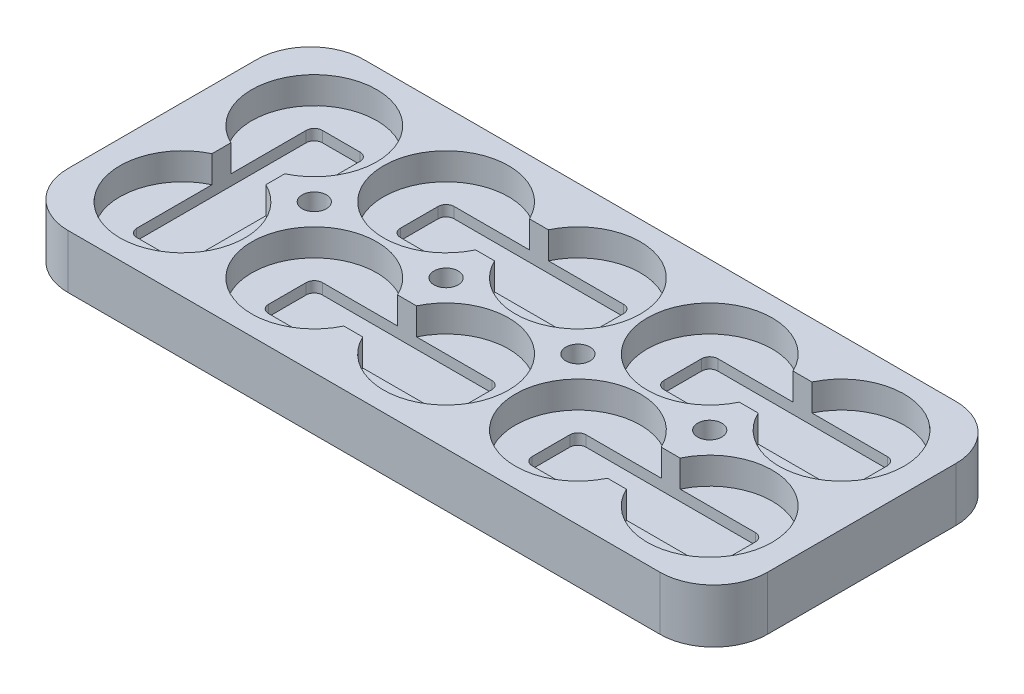
from build123d import *

# Parameters (mm, degrees)
SKIZZE1_W                                   = 130
SKIZZE1_H                                   = 55
AUFSATZ_LINEAR_AUSTRAGEN1_DEPTH             = 10
VERRUNDUNG1_R                               = 10
DURCHGANGSLOCH_F_R_M41_D                    = 4.5
SKIZZE3_R                                   = 11.625
SCHNITT_LINEAR_AUSTRAGEN1_DEPTH             = 5
SKIZZE8_W                                   = 34.5
SKIZZE8_H                                   = 10
SKIZZE8_W_2                                 = 10
SKIZZE8_H_2                                 = 34.5
SCHNITT_LINEAR_AUSTRAGEN3_DEPTH             = 2
SCHNITT_LINEAR_AUSTRAGEN3_DIRECTION_2_REACH = 7
VERRUNDUNG3_R                               = 1.5


with BuildPart() as part:
    # Skizze1 → Aufsatz-Linear austragen1 (new body)
    with BuildSketch(Plane(origin=(0, 0, 0), x_dir=(1, 0, 0), z_dir=(0, 1, 0))):
        with Locations((65, 27.5)):
            Rectangle(SKIZZE1_W, SKIZZE1_H)
    extrude(amount=AUFSATZ_LINEAR_AUSTRAGEN1_DEPTH)

    # Verrundung1
    verrundung1_edges = [part.edges().sort_by_distance(p)[0] for p in [
        (0, 5, -55),
        (130, 5, -55),
        (130, 5, 0),
        (0, 5, 0),
    ]]
    fillet(verrundung1_edges, radius=VERRUNDUNG1_R)

    # Durchgangsloch für M41 (through all)
    with Locations(Plane(origin=(0, 0, 0), x_dir=(-1, 0, 0), z_dir=(0, -1, 0))):
        with Locations((-77.25, 27.5), (-52.75, 27.5), (-28.25, 27.5), (-101.75, 27.5)):
            Hole(DURCHGANGSLOCH_F_R_M41_D / 2)

    # Skizze3 → Schnitt-Linear austragen1 (cut)
    with BuildSketch(Plane(origin=(0, 10, 0), x_dir=(1, 0, 0), z_dir=(0, 1, 0))):
        with Locations((16, 15.25)):
            Circle(SKIZZE3_R)
        with Locations((40.5, 15.25)):
            Circle(SKIZZE3_R)
        with Locations((65, 15.25)):
            Circle(SKIZZE3_R)
        with Locations((89.5, 15.25)):
            Circle(SKIZZE3_R)
        with Locations((114, 15.25)):
            Circle(SKIZZE3_R)
        with Locations((40.5, 39.75)):
            Circle(SKIZZE3_R)
        with Locations((65, 39.75)):
            Circle(SKIZZE3_R)
        with Locations((89.5, 39.75)):
            Circle(SKIZZE3_R)
        with Locations((114, 39.75)):
            Circle(SKIZZE3_R)
        with Locations((16, 39.75)):
            Circle(SKIZZE3_R)
    extrude(amount=-SCHNITT_LINEAR_AUSTRAGEN1_DEPTH, mode=Mode.SUBTRACT)

    # Skizze8 → Schnitt-Linear austragen3 (cut)
    with BuildSketch(Plane(origin=(0, 5, 0), x_dir=(1, 0, 0), z_dir=(0, 1, 0))):
        with Locations((101.75, 39.75)):
            Rectangle(SKIZZE8_W, SKIZZE8_H)
        with Locations((101.75, 15.25)):
            Rectangle(SKIZZE8_W, SKIZZE8_H)
        with Locations((52.75, 39.75)):
            Rectangle(SKIZZE8_W, SKIZZE8_H)
        with Locations((52.75, 15.25)):
            Rectangle(SKIZZE8_W, SKIZZE8_H)
        with Locations((16, 27.5)):
            Rectangle(SKIZZE8_W_2, SKIZZE8_H_2)
    extrude(amount=-SCHNITT_LINEAR_AUSTRAGEN3_DEPTH, mode=Mode.SUBTRACT)

    # Skizze8 → Schnitt-Linear austragen3 direction 2 (cut, up to next)
    with BuildSketch(Plane(origin=(0, 5, 0), x_dir=(1, 0, 0), z_dir=(0, 1, 0)), mode=Mode.PRIVATE) as schnitt_linear_austragen3_direction_2_sk1:
        with Locations((101.75, 39.75)):
            Rectangle(SKIZZE8_W, SKIZZE8_H)
    schnitt_linear_austragen3_direction_2_tool1 = extrude(schnitt_linear_austragen3_direction_2_sk1.sketch, amount=SCHNITT_LINEAR_AUSTRAGEN3_DIRECTION_2_REACH, mode=Mode.PRIVATE) & part.part
    add(schnitt_linear_austragen3_direction_2_tool1.solids().sort_by_distance((101.75, 5, -39.75))[0], mode=Mode.SUBTRACT)
    # Skizze8 → Schnitt-Linear austragen3 direction 2 (cut, up to next)
    with BuildSketch(Plane(origin=(0, 5, 0), x_dir=(1, 0, 0), z_dir=(0, 1, 0)), mode=Mode.PRIVATE) as schnitt_linear_austragen3_direction_2_sk2:
        with Locations((101.75, 15.25)):
            Rectangle(SKIZZE8_W, SKIZZE8_H)
    schnitt_linear_austragen3_direction_2_tool2 = extrude(schnitt_linear_austragen3_direction_2_sk2.sketch, amount=SCHNITT_LINEAR_AUSTRAGEN3_DIRECTION_2_REACH, mode=Mode.PRIVATE) & part.part
    add(schnitt_linear_austragen3_direction_2_tool2.solids().sort_by_distance((101.75, 5, -15.25))[0], mode=Mode.SUBTRACT)
    # Skizze8 → Schnitt-Linear austragen3 direction 2 (cut, up to next)
    with BuildSketch(Plane(origin=(0, 5, 0), x_dir=(1, 0, 0), z_dir=(0, 1, 0)), mode=Mode.PRIVATE) as schnitt_linear_austragen3_direction_2_sk3:
        with Locations((52.75, 39.75)):
            Rectangle(SKIZZE8_W, SKIZZE8_H)
    schnitt_linear_austragen3_direction_2_tool3 = extrude(schnitt_linear_austragen3_direction_2_sk3.sketch, amount=SCHNITT_LINEAR_AUSTRAGEN3_DIRECTION_2_REACH, mode=Mode.PRIVATE) & part.part
    add(schnitt_linear_austragen3_direction_2_tool3.solids().sort_by_distance((52.75, 5, -39.75))[0], mode=Mode.SUBTRACT)
    # Skizze8 → Schnitt-Linear austragen3 direction 2 (cut, up to next)
    with BuildSketch(Plane(origin=(0, 5, 0), x_dir=(1, 0, 0), z_dir=(0, 1, 0)), mode=Mode.PRIVATE) as schnitt_linear_austragen3_direction_2_sk4:
        with Locations((52.75, 15.25)):
            Rectangle(SKIZZE8_W, SKIZZE8_H)
    schnitt_linear_austragen3_direction_2_tool4 = extrude(schnitt_linear_austragen3_direction_2_sk4.sketch, amount=SCHNITT_LINEAR_AUSTRAGEN3_DIRECTION_2_REACH, mode=Mode.PRIVATE) & part.part
    add(schnitt_linear_austragen3_direction_2_tool4.solids().sort_by_distance((52.75, 5, -15.25))[0], mode=Mode.SUBTRACT)
    # Skizze8 → Schnitt-Linear austragen3 direction 2 (cut, up to next)
    with BuildSketch(Plane(origin=(0, 5, 0), x_dir=(1, 0, 0), z_dir=(0, 1, 0)), mode=Mode.PRIVATE) as schnitt_linear_austragen3_direction_2_sk5:
        with Locations((16, 27.5)):
            Rectangle(SKIZZE8_W_2, SKIZZE8_H_2)
    schnitt_linear_austragen3_direction_2_tool5 = extrude(schnitt_linear_austragen3_direction_2_sk5.sketch, amount=SCHNITT_LINEAR_AUSTRAGEN3_DIRECTION_2_REACH, mode=Mode.PRIVATE) & part.part
    add(schnitt_linear_austragen3_direction_2_tool5.solids().sort_by_distance((16, 5, -27.5))[0], mode=Mode.SUBTRACT)

    # Verrundung3
    verrundung3_edges = [part.edges().sort_by_distance(p)[0] for p in [
        (21, 4, -44.75),
        (70, 4, -20.25),
        (70, 4, -44.75),
        (119, 4, -44.75),
        (119, 4, -20.25),
        (11, 4, -10.25),
        (35.5, 4, -34.75),
        (84.5, 4, -34.75),
        (84.5, 4, -10.25),
        (35.5, 4, -10.25),
        (21, 4, -10.25),
        (70, 4, -34.75),
        (70, 4, -10.25),
        (119, 4, -34.75),
        (119, 4, -10.25),
        (35.5, 4, -20.25),
        (84.5, 4, -20.25),
        (84.5, 4, -44.75),
        (35.5, 4, -44.75),
        (11, 4, -44.75),
    ]]
    fillet(verrundung3_edges, radius=VERRUNDUNG3_R)


solid = part.part
